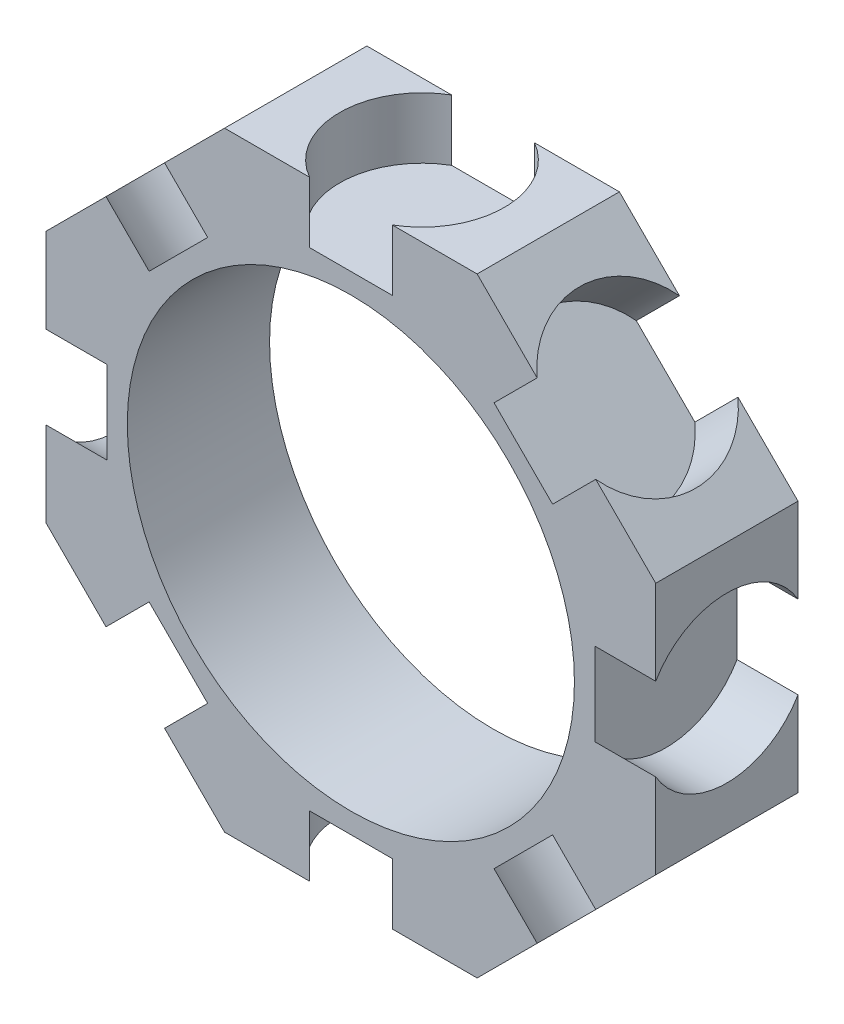
from build123d import *

# Parameters (mm, degrees)
SKETCH1_R           = 11
BOSS_EXTRUDE1_DEPTH = 3.5
SKETCH2_R           = 4.05
CUT_EXTRUDE3_DEPTH  = 3
CIRPATTERN1_COUNT   = 8


with BuildPart() as part:
    # Sketch1 → Boss-Extrude1 (new, symmetric)
    with BuildSketch(Plane.XY):
        Polygon((6.213203436, 15), (-6.213203436, 15), (-15, 6.213203436), (-15, -6.213203436), (-6.213203436, -15), (6.213203436, -15), (15, -6.213203436), (15, 6.213203436), align=None)
        Circle(SKETCH1_R, mode=Mode.SUBTRACT)
    extrude(amount=BOSS_EXTRUDE1_DEPTH, both=True)

    # Sketch2 → Cut-Extrude3 (cut)
    with BuildSketch(Plane(origin=(0, -15, 0), x_dir=(-1, 0, 0), z_dir=(0, -1, 0))):
        Circle(SKETCH2_R)
    cut_extrude3 = extrude(amount=-CUT_EXTRUDE3_DEPTH, mode=Mode.SUBTRACT)

    # CirPattern1: Cut-Extrude3 ×8 about axis
    cirpattern1_axis = Axis((0, 0, 3.5), (0, 0, 1))
    for i in range(1, CIRPATTERN1_COUNT):
        add(cut_extrude3.rotate(cirpattern1_axis, i * 360 / CIRPATTERN1_COUNT), mode=Mode.SUBTRACT)


solid = part.part
